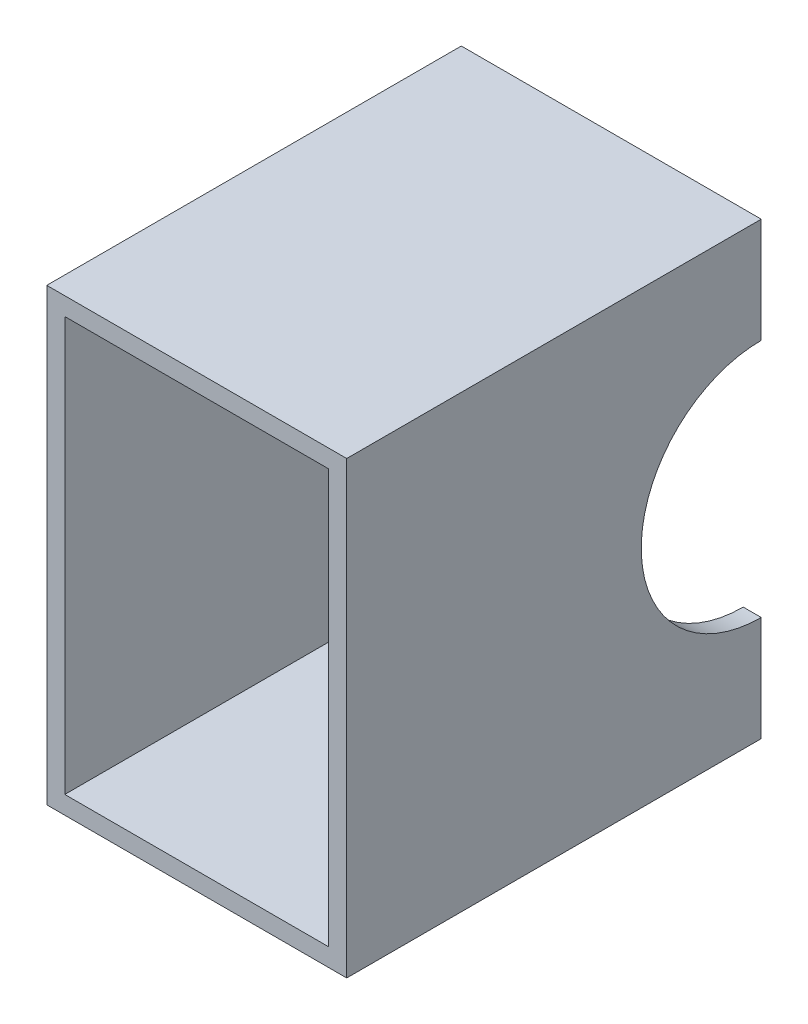
from build123d import *

# Parameters (mm, degrees)
SKETCH1_W               = 100
SKETCH1_H               = 150
SKETCH1_W_2             = 88
SKETCH1_H_2             = 138
BOSS_EXTRUDE1_DEPTH     = 138.202315188
SKETCH2_R               = 40
CUT_EXTRUDE1_DEPTH      = 51
CUT_EXTRUDE1_DEPTH_BACK = 51


with BuildPart() as part:
    # Sketch1 → Boss-Extrude1 (new body)
    with BuildSketch(Plane.XY):
        Rectangle(SKETCH1_W, SKETCH1_H)
        Rectangle(SKETCH1_W_2, SKETCH1_H_2, mode=Mode.SUBTRACT)
    extrude(amount=BOSS_EXTRUDE1_DEPTH)

    # Sketch2 → Cut-Extrude1 (cut, two sides)
    with BuildSketch(Plane(origin=(0, 0, 0), x_dir=(0, 0, -1), z_dir=(1, 0, 0))) as cut_extrude1_sk:
        Circle(SKETCH2_R)
    extrude(amount=CUT_EXTRUDE1_DEPTH, mode=Mode.SUBTRACT)
    extrude(cut_extrude1_sk.sketch, amount=-CUT_EXTRUDE1_DEPTH_BACK, mode=Mode.SUBTRACT)


solid = part.part
